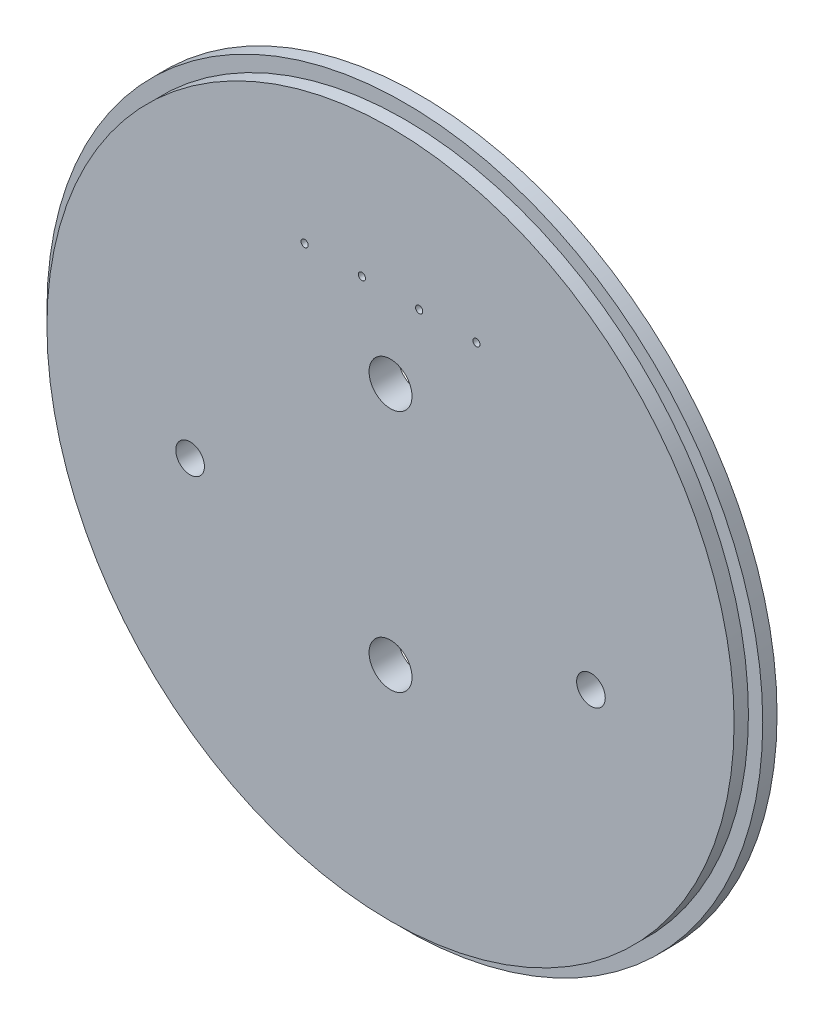
from build123d import *

# Parameters (mm, degrees)
SKETCH1_R                      = 79.375
BOSS_EXTRUDE1_DEPTH            = 3.175
SKETCH2_R                      = 76.2
BOSS_EXTRUDE2_DEPTH            = 3.175
F_1_4_0_25_DIAMETER_HOLE1_D    = 6.35
F_1_16_0_0625_DIAMETER_HOLE1_D = 1.5875
F_3_8_0_375_DIAMETER_HOLE1_D   = 9.525


with BuildPart() as part:
    # Sketch1 → Boss-Extrude1 (new body)
    with BuildSketch(Plane.XY):
        Circle(SKETCH1_R)
    extrude(amount=BOSS_EXTRUDE1_DEPTH)

    # Sketch2 → Boss-Extrude2 (add)
    with BuildSketch(Plane.XY.offset(3.175)):
        Circle(SKETCH2_R)
    extrude(amount=BOSS_EXTRUDE2_DEPTH)

    # 1/4 (0.25) Diameter Hole1 (through all)
    with Locations(Plane.XY.offset(6.35)):
        with Locations((-44.45, -9.525), (44.45, -9.525)):
            Hole(F_1_4_0_25_DIAMETER_HOLE1_D / 2)

    # 1/16 (0.0625) Diameter Hole1 (through all)
    with Locations(Plane.XY.offset(6.35)):
        with Locations((-19.05, 44.45), (-6.35, 44.45), (6.35, 44.45), (19.05, 44.45)):
            Hole(F_1_16_0_0625_DIAMETER_HOLE1_D / 2)

    # 3/8 (0.375) Diameter Hole1 (through all)
    with Locations(Plane.XY.offset(6.35)):
        with Locations((0, -26.9875), (0, 26.9875)):
            Hole(F_3_8_0_375_DIAMETER_HOLE1_D / 2)


solid = part.part
